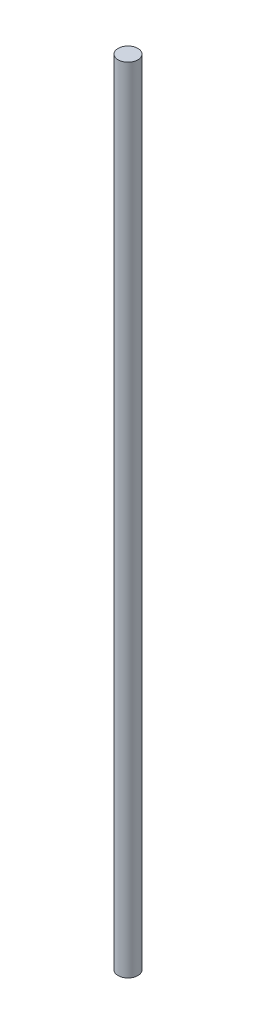
from build123d import *

# Parameters (mm, degrees)
SKETCH_1_R      = 5
EXTRUDE_2_DEPTH = 400


with BuildPart() as part:
    # 草图1 → 凸台-拉伸2 (new body)
    with BuildSketch(Plane(origin=(0, 0, 0), x_dir=(1, 0, 0), z_dir=(0, 1, 0))):
        Circle(SKETCH_1_R)
    extrude(amount=EXTRUDE_2_DEPTH)


solid = part.part
